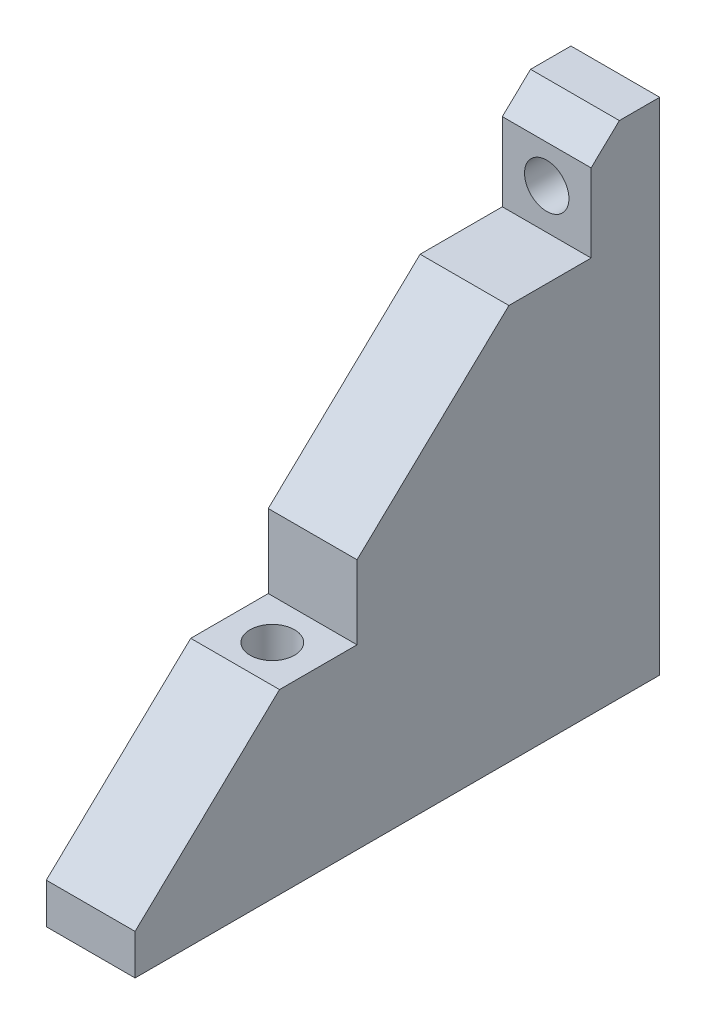
from build123d import *

# Parameters (mm, degrees)
SKETCH1_W           = 65
SKETCH1_H           = 57
BOSS_EXTRUDE1_DEPTH = 5
SKETCH2_W           = 65
SKETCH2_H           = 65
SKETCH2_R           = 2.75
SKETCH2_R_2         = 5
BOSS_EXTRUDE2_DEPTH = 5
SKETCH3_W           = 11
SKETCH3_H           = 60
BOSS_EXTRUDE7_DEPTH = 57
CUT_EXTRUDE2_DEPTH  = 165.705798319
SKETCH6_R           = 2.75
CUT_EXTRUDE3_DEPTH  = 89.911472826
SKETCH7_R           = 2.75
CUT_EXTRUDE4_DEPTH  = 160.515673211
CUT_EXTRUDE5_START  = 57
SKETCH8_W           = 11
SKETCH8_H           = 10
CUT_EXTRUDE5_DEPTH  = 40
CUT_EXTRUDE6_START  = 60
SKETCH9_W           = 11
SKETCH9_H           = 10
CUT_EXTRUDE6_DEPTH  = 56.5
SKETCH10_W          = 7
SKETCH10_H          = 62
SKETCH10_W_2        = 29
CUT_EXTRUDE7_DEPTH  = 160.515673211


with BuildPart() as part:
    # Sketch1 → Boss-Extrude1 (new body)
    with BuildSketch(Plane.XY):
        with Locations((0, -108.5)):
            Rectangle(SKETCH1_W, SKETCH1_H)
    extrude(amount=-BOSS_EXTRUDE1_DEPTH)

    # Sketch2 → Boss-Extrude2 (add)
    with BuildSketch(Plane.XZ.offset(137)):
        with Locations((0, 27.5)):
            Rectangle(SKETCH2_W, SKETCH2_H)
        with Locations(Location((20, 37.5, 0), (0, 0, 270))):
            Circle(SKETCH2_R, mode=Mode.SUBTRACT)
        with Locations(Location((21, 47.5, 0), (0, 0, 270))):
            Circle(SKETCH2_R_2, mode=Mode.SUBTRACT)
        with Locations(Location((-20, 47.5, 0), (0, 0, 270))):
            Circle(SKETCH2_R_2, mode=Mode.SUBTRACT)
        with Locations(Location((-20, 7.5, 0), (0, 0, 90))):
            Circle(SKETCH2_R_2, mode=Mode.SUBTRACT)
        with Locations(Location((21, 7.5, 0), (0, 0, 90))):
            Circle(SKETCH2_R_2, mode=Mode.SUBTRACT)
        with Locations(Location((-20, 37.5, 0), (0, 0, 90))):
            Circle(SKETCH2_R, mode=Mode.SUBTRACT)
    extrude(amount=BOSS_EXTRUDE2_DEPTH)

    # Sketch3 → Boss-Extrude7 (add)
    with BuildSketch(Plane(origin=(0, -137, 0), x_dir=(1, 0, 0), z_dir=(0, 1, 0))):
        with Locations((20, -30)):
            Rectangle(SKETCH3_W, SKETCH3_H)
        with Locations((-20, -30)):
            Rectangle(SKETCH3_W, SKETCH3_H)
    extrude(amount=BOSS_EXTRUDE7_DEPTH)

    # Sketch5 → Cut-Extrude2 (cut, through all)
    with BuildSketch(Plane(origin=(25.5, 0, 0), x_dir=(0, 0, -1), z_dir=(1, 0, 0))):
        Polygon((-60, -137), (0, -80), (-60, -80), align=None)
    extrude(amount=-CUT_EXTRUDE2_DEPTH, mode=Mode.SUBTRACT)

    # Sketch6 → Cut-Extrude3 (cut, through all)
    with BuildSketch(Plane.XZ.offset(137)):
        with Locations(Location((-20, 37.5, 0), (0, 0, 90))):
            Circle(SKETCH6_R)
        with Locations(Location((20, 37.5, 0), (0, 0, 90))):
            Circle(SKETCH6_R)
    extrude(amount=-CUT_EXTRUDE3_DEPTH, mode=Mode.SUBTRACT)

    # Sketch7 → Cut-Extrude4 (cut, through all)
    with BuildSketch(Plane.XY.offset(60)):
        with Locations((-20, -88)):
            Circle(SKETCH7_R)
        with Locations(Location((20, -88, 0), (0, 0, 270))):
            Circle(SKETCH7_R)
    extrude(amount=-CUT_EXTRUDE4_DEPTH, mode=Mode.SUBTRACT)

    # Sketch8 → Cut-Extrude5 (cut)
    with BuildSketch(Plane(origin=(0, -137, 0), x_dir=(1, 0, 0), z_dir=(0, 1, 0)).offset(CUT_EXTRUDE5_START)):
        with Locations((20, -37.5)):
            Rectangle(SKETCH8_W, SKETCH8_H)
        with Locations((-20, -37.5)):
            Rectangle(SKETCH8_W, SKETCH8_H)
    extrude(amount=-CUT_EXTRUDE5_DEPTH, mode=Mode.SUBTRACT)

    # Sketch9 → Cut-Extrude6 (cut)
    with BuildSketch(Plane.XY.offset(CUT_EXTRUDE6_START)):
        with Locations((-20, -88)):
            Rectangle(SKETCH9_W, SKETCH9_H)
        with Locations((20, -88)):
            Rectangle(SKETCH9_W, SKETCH9_H)
    extrude(amount=-CUT_EXTRUDE6_DEPTH, mode=Mode.SUBTRACT)

    # Sketch10 → Cut-Extrude7 (cut, through all)
    with BuildSketch(Plane.XY.offset(60)):
        with Locations((-29, -111)):
            Rectangle(SKETCH10_W, SKETCH10_H)
        with Locations((0, -111)):
            Rectangle(SKETCH10_W_2, SKETCH10_H)
        with Locations((29, -111)):
            Rectangle(SKETCH10_W, SKETCH10_H)
    extrude(amount=-CUT_EXTRUDE7_DEPTH, mode=Mode.SUBTRACT)


with BuildPart() as cut_extrude7_piece_1:
    # of the separate pieces the step leaves, piece 1, a body of its own (cut_extrude7_pieces)
    add(part.part.solids().sort_by_distance((25.5, -80, 0))[0])


with BuildPart() as cut_extrude7_piece_2:
    # of the separate pieces the step leaves, piece 2, a body of its own (cut_extrude7_pieces)
    add(part.part.solids().sort_by_distance((-14.5, -80, 0))[0])


solid = cut_extrude7_piece_2.part
